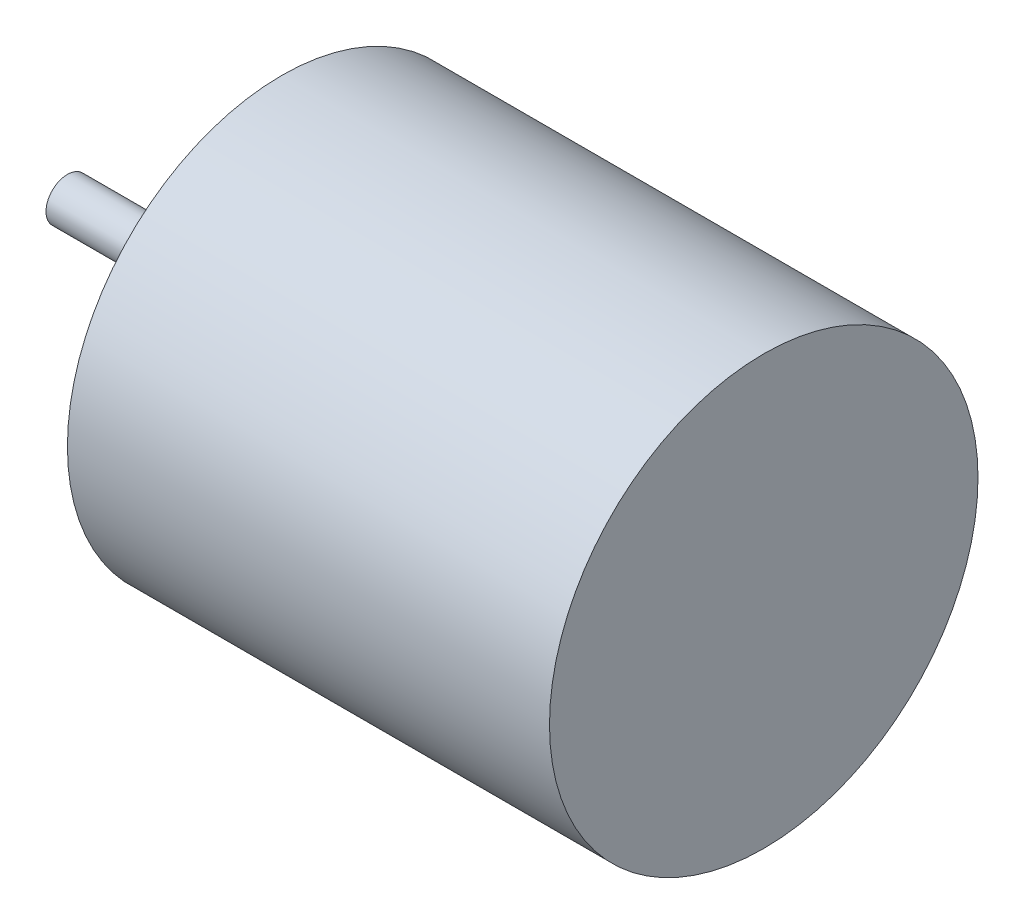
from build123d import *

# Parameters (mm, degrees)
SKETCH1_W   = 4
SKETCH1_H   = 0.4
SKETCH1_W_2 = 9
SKETCH1_H_2 = 4


with BuildPart() as part:
    # Sketch1 → Revolve1 (revolve)
    with BuildSketch(Plane.XY):
        with Locations((-2, 0.2)):
            Rectangle(SKETCH1_W, SKETCH1_H)
        with Locations((4.5, 2)):
            Rectangle(SKETCH1_W_2, SKETCH1_H_2)
    revolve(axis=Axis((9, 0, 0), (-1, 0, 0)))


solid = part.part
